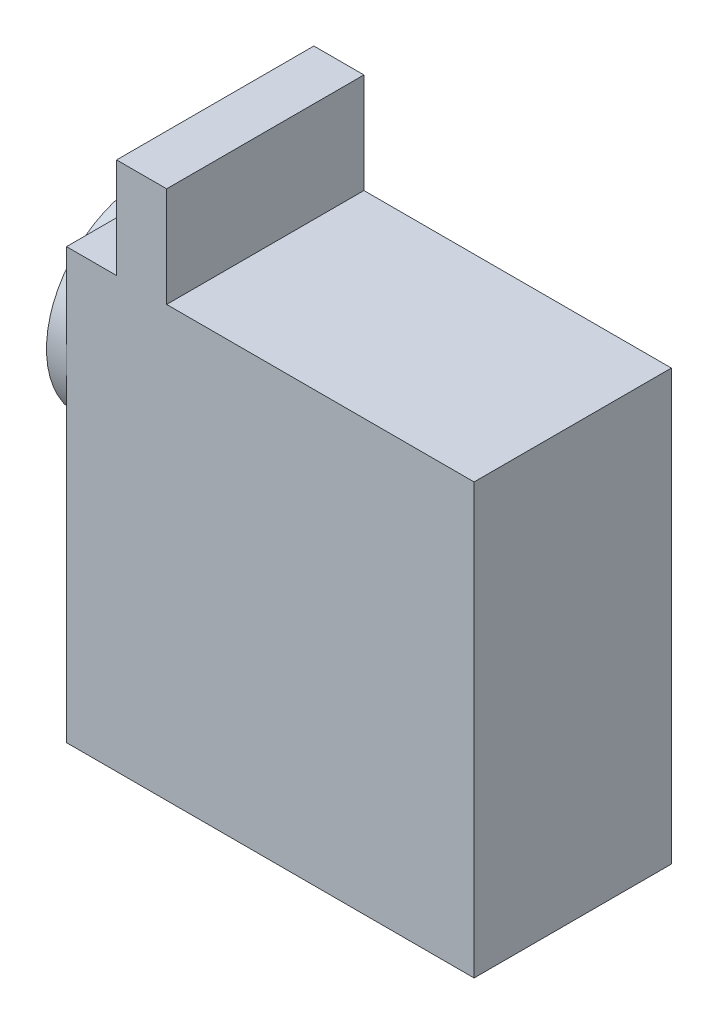
from build123d import *

# Parameters (mm, degrees)
SKETCH_1_W      = 40.7
SKETCH_1_H      = 42.9
EXTRUDE_1_DEPTH = 19.7
SKETCH_2_W      = 5
SKETCH_2_H      = 19.7
EXTRUDE_2_DEPTH = 10
SKETCH_3_R      = 9.85
EXTRUDE_3_DEPTH = 2
SKETCH_4_R      = 2.5
EXTRUDE_4_DEPTH = 5


with BuildPart() as part:
    # 草圖1 → 填料-伸長1 (new body)
    with BuildSketch(Plane.XY):
        with Locations((20.35, -21.45)):
            Rectangle(SKETCH_1_W, SKETCH_1_H)
    extrude(amount=EXTRUDE_1_DEPTH)

    # 草圖2 → 填料-伸長2 (add)
    with BuildSketch(Plane(origin=(0, 0, 0), x_dir=(1, 0, 0), z_dir=(0, 1, 0))):
        with Locations((7.5, -9.85)):
            Rectangle(SKETCH_2_W, SKETCH_2_H)
    extrude(amount=EXTRUDE_2_DEPTH)

    # 草圖3 → 填料-伸長3 (add)
    with BuildSketch(Plane.ZY):
        with Locations((9.85, -9.85)):
            Circle(SKETCH_3_R)
    extrude(amount=EXTRUDE_3_DEPTH)

    # 草圖4 → 填料-伸長4 (add)
    with BuildSketch(Plane.ZY.offset(2)):
        with Locations((9.85, -9.85)):
            Circle(SKETCH_4_R)
    extrude(amount=EXTRUDE_4_DEPTH)


solid = part.part
